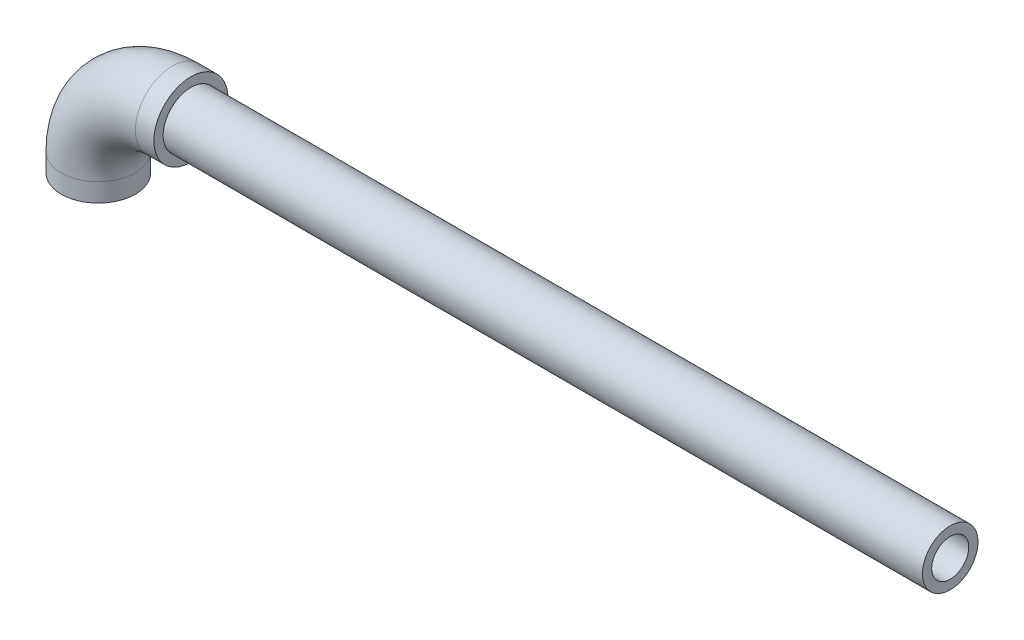
from build123d import *

# Parameters (mm, degrees)
SKETCH1_R           = 20
SKETCH1_R_2         = 15
SKETCH3_R           = 15
SKETCH3_R_2         = 10
BOSS_EXTRUDE1_DEPTH = 410


with BuildPart() as part:
    # Sweep1: sweep along a path in Sketch2
    with BuildLine(Plane.XY) as sweep1_path:
        Line((0, 0), (0, 10))
        ThreePointArc((0, 10), (11.715728753, 38.284271247), (40, 50))
        Line((40, 50), (50, 50))
    # Sketch1 → Sweep1 (sweep)
    with BuildSketch(Plane(origin=(0, 0, 0), x_dir=(1, 0, 0), z_dir=(0, 1, 0))):
        Circle(SKETCH1_R)
        Circle(SKETCH1_R_2, mode=Mode.SUBTRACT)
    sweep(path=sweep1_path.line)


with BuildPart() as body_2:
    # Sketch3 → Boss-Extrude1 (new body)
    with BuildSketch(Plane(origin=(50, 0, 0), x_dir=(0, 0, -1), z_dir=(1, 0, 0))):
        with Locations((0, 50)):
            Circle(SKETCH3_R)
        with Locations((0, 50)):
            Circle(SKETCH3_R_2, mode=Mode.SUBTRACT)
    extrude(amount=BOSS_EXTRUDE1_DEPTH)


solid = Compound([part.part, body_2.part])
